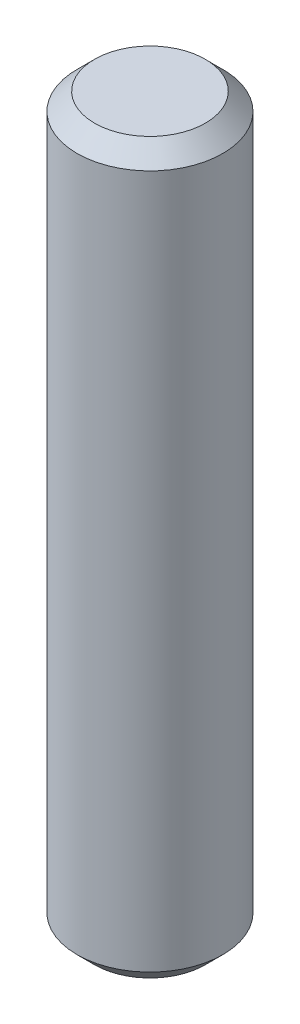
from build123d import *

# Parameters (mm, degrees)
SKETCH1_R           = 6.35
BOSS_EXTRUDE1_DEPTH = 63.5
CHAMFER1_SIZE       = 1.524


with BuildPart() as part:
    # Sketch1 → Boss-Extrude1 (new body)
    with BuildSketch(Plane(origin=(0, 0, 0), x_dir=(1, 0, 0), z_dir=(0, 1, 0))):
        Circle(SKETCH1_R)
    extrude(amount=BOSS_EXTRUDE1_DEPTH)

    # Chamfer1
    chamfer1_edges = [part.edges().sort_by_distance(p)[0] for p in [
        (-6.35, 0, 0),
        (-6.35, 63.5, 0),
    ]]
    chamfer(chamfer1_edges, length=CHAMFER1_SIZE)


solid = part.part
